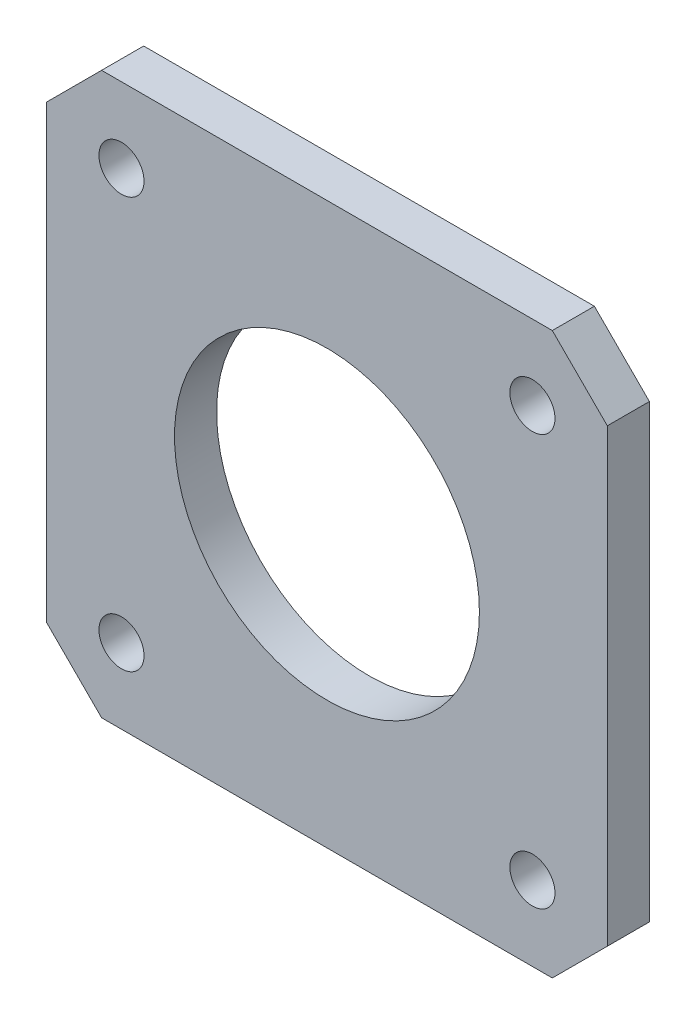
from build123d import *

# Parameters (mm, degrees)
BOSS_EXTRUDE1_DEPTH      = 3.175
SKETCH2_R                = 11.5
CUT_EXTRUDE1_DEPTH       = 4.175
M3_CLEARANCE_HOLE1_D     = 3.4
M3_CLEARANCE_HOLE1_DEPTH = 3.175


with BuildPart() as part:
    # Sketch1 → Boss-Extrude1 (new body)
    with BuildSketch(Plane.XY):
        Polygon((-17, -21.15), (17, -21.15), (21.15, -17), (21.15, 17), (17, 21.15), (-17, 21.15), (-21.15, 17), (-21.15, -17), align=None)
    extrude(amount=BOSS_EXTRUDE1_DEPTH)

    # Sketch2 → Cut-Extrude1 (cut, through all)
    with BuildSketch(Plane.XY.offset(3.175)):
        Circle(SKETCH2_R)
    extrude(amount=-CUT_EXTRUDE1_DEPTH, mode=Mode.SUBTRACT)

    # M3 Clearance Hole1
    with Locations(Plane.XY.offset(3.175)):
        with Locations((-15.5, 15.5), (15.5, 15.5), (15.5, -15.5), (-15.5, -15.5)):
            Hole(M3_CLEARANCE_HOLE1_D / 2, depth=M3_CLEARANCE_HOLE1_DEPTH)


solid = part.part
